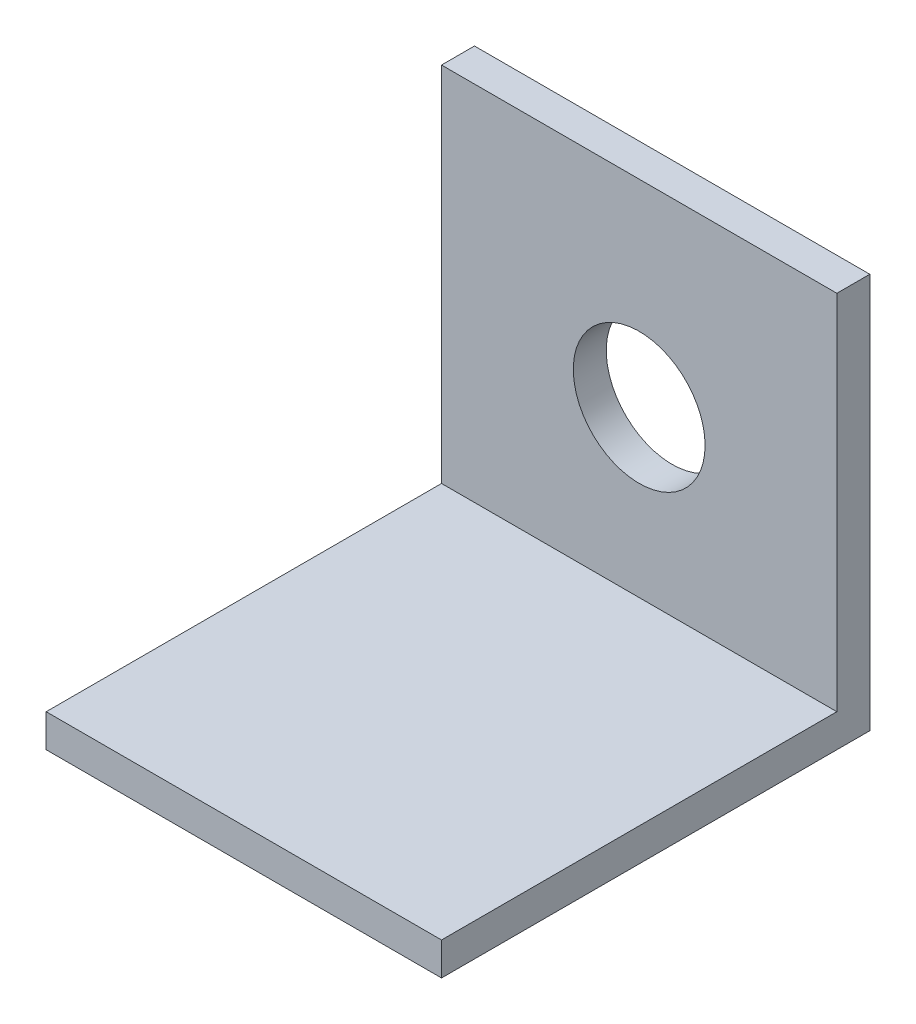
from build123d import *

# Parameters (mm, degrees)
SKETCH1_W           = 19.05
SKETCH1_H           = 19.05
SKETCH1_R           = 3.175
BOSS_EXTRUDE1_DEPTH = 0.79375
SKETCH2_W           = 19.05
SKETCH2_H           = 19.05
BOSS_EXTRUDE2_DEPTH = 1.5875


with BuildPart() as part:
    # Sketch1 → Boss-Extrude1 (new body, symmetric)
    with BuildSketch(Plane.XY):
        Rectangle(SKETCH1_W, SKETCH1_H)
        Circle(SKETCH1_R, mode=Mode.SUBTRACT)
    extrude(amount=BOSS_EXTRUDE1_DEPTH, both=True)

    # Sketch2 → Boss-Extrude2 (add)
    with BuildSketch(Plane.XZ.offset(9.525)):
        with Locations((0, 10.31875)):
            Rectangle(SKETCH2_W, SKETCH2_H)
    extrude(amount=-BOSS_EXTRUDE2_DEPTH)


solid = part.part
